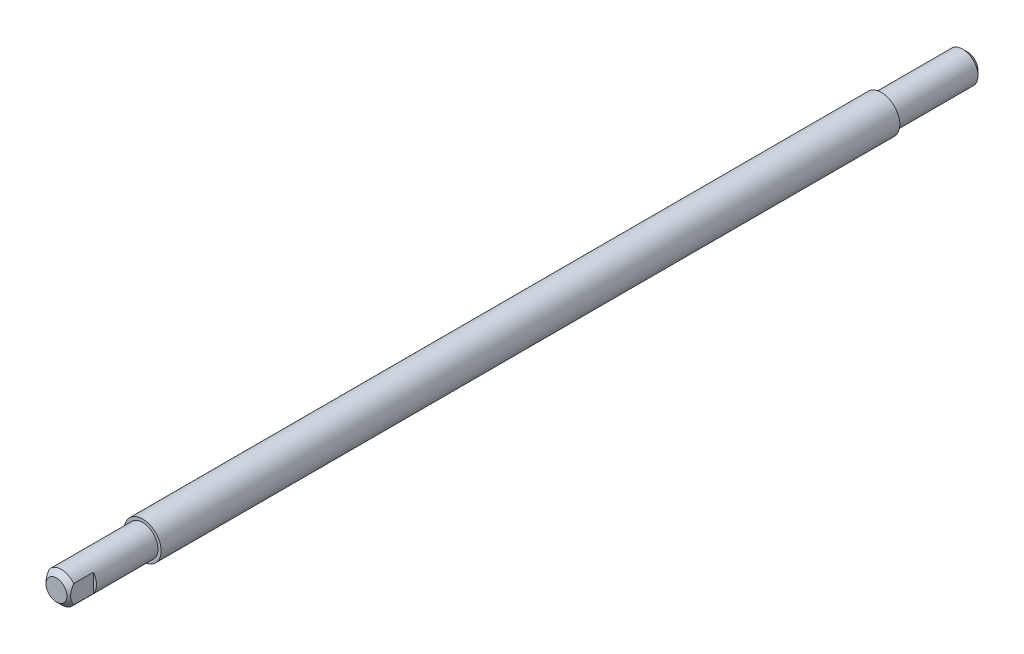
from build123d import *

# Parameters (mm, degrees)
SKETCH1_R               = 3.96875
EXTRUDE1_DEPTH          = 234.95
CHAMFER1_SIZE           = 1.27
SKETCH3_W               = 0.79375
SKETCH3_H               = 6.35
CUT_EXTRUDE1_DEPTH      = 4.96875
CUT_EXTRUDE1_DEPTH_BACK = 4.96875
SKETCH4_W               = 0.79375
SKETCH4_H               = 190.5


with BuildPart() as part:
    # Sketch1 → Extrude1 (new body)
    with BuildSketch(Plane.XY):
        Circle(SKETCH1_R)
    extrude(amount=EXTRUDE1_DEPTH)

    # Chamfer1
    chamfer1_edges = [part.edges().sort_by_distance(p)[0] for p in [
        (-3.96875, 0, 0),
        (-3.96875, 0, 234.95),
    ]]
    chamfer(chamfer1_edges, length=CHAMFER1_SIZE)

    # Sketch3 → Cut-Extrude1 (cut, two sides)
    with BuildSketch(Plane(origin=(0, 0, 0), x_dir=(1, 0, 0), z_dir=(0, 1, 0))) as cut_extrude1_sk:
        with Locations((3.571875, -231.775)):
            Rectangle(SKETCH3_W, SKETCH3_H)
        with Locations((-3.571875, -231.775)):
            Rectangle(SKETCH3_W, SKETCH3_H)
    extrude(amount=CUT_EXTRUDE1_DEPTH, mode=Mode.SUBTRACT)
    extrude(cut_extrude1_sk.sketch, amount=-CUT_EXTRUDE1_DEPTH_BACK, mode=Mode.SUBTRACT)

    # Sketch4 → Revolve1 (revolve)
    with BuildSketch(Plane(origin=(0, 0, 0), x_dir=(1, 0, 0), z_dir=(0, 1, 0)), mode=Mode.PRIVATE) as revolve1_sk:
        with Locations((-4.365625, -117.475)):
            Rectangle(SKETCH4_W, SKETCH4_H)
    revolve(revolve1_sk.sketch.rotate(Axis((0, 0, -16.320632547), (0, 0, 1)), 323.130102354), axis=Axis((0, 0, -16.320632547), (0, 0, 1)))  # turned: the seam where the file's is


solid = part.part
